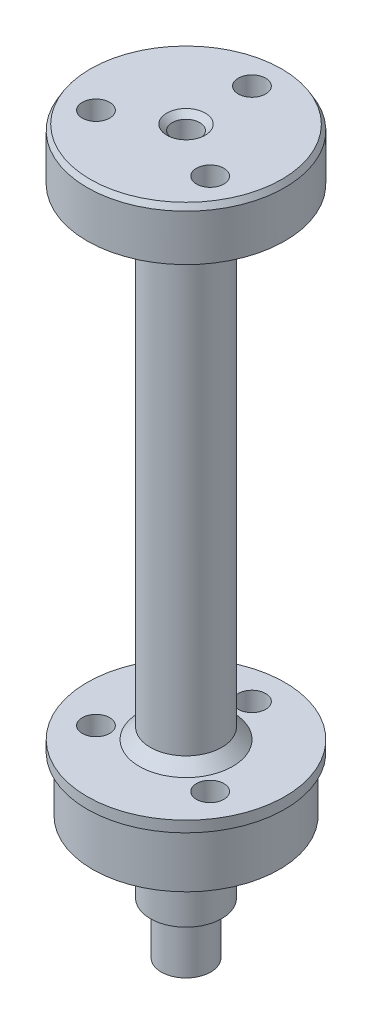
from build123d import *

# Parameters (mm, degrees)
HOLE_WIZARD_M3_1_D           = 2.5
CHAMFER_1_SIZE               = 1
CHAMFER_2_SIZE               = 0.5
CHAMFER_2_SIZE2              = 0.288675135
CHAMFER_2_PART_2_SIZE        = 0.5
CHAMFER_2_PART_2_SIZE2       = 0.288675135
CHAMFER_2_PART_3_SIZE        = 0.5
CHAMFER_2_PART_3_SIZE2       = 0.288675135
HOLE_WIZARD_M3_2_D           = 2.5
HOLE_WIZARD_M3_2_DEPTH       = 6
HOLE_WIZARD_M3_2_CSINK_D     = 3.5
HOLE_WIZARD_M3_2_CSINK_ANGLE = 90
HOLE_WIZARD_M3_2_TIP         = 0.751075774


with BuildPart() as part:
    # 草图2 → 旋转1 (revolve)
    with BuildSketch(Plane.XY):
        Polygon((3.25, 0), (8.5, 0), (8.5, 5), (9, 5), (9, 6), (3.25, 6), (3.25, 49.5), (9, 49.5), (9, 54.5), (1.25, 54.5), (1.25, -11.5), (2.25, -11.5), (2.25, -6.5), (3.25, -6.5), align=None)
    revolve(axis=Axis((0, 60, 0), (0, -1, 0)))

    # M3 螺纹孔1 (through all)
    with Locations(Plane(origin=(0, 54.5, 0), x_dir=(1, 0, 0), z_dir=(0, 1, 0))):
        with Locations((-5.196152423, -3), (0, 6), (5.196152423, -3)):
            Hole(HOLE_WIZARD_M3_1_D / 2)

    # 倒角1
    chamfer_1_edges = [part.edges().sort_by_distance(p)[0] for p in [
        (-3.25, 6, 0),
        (-3.25, 49.5, 0),
    ]]
    chamfer(chamfer_1_edges, length=CHAMFER_1_SIZE)

    # 倒角2
    chamfer_2_edges = [part.edges().sort_by_distance(p)[0] for p in [
        (-9, 49.5, 0),
    ]]
    chamfer_2_side = [part.faces().sort_by_distance(p)[0] for p in [
        (-4.504558441, 49.5, 0),
    ]]
    chamfer(chamfer_2_edges, length=CHAMFER_2_SIZE, length2=CHAMFER_2_SIZE2, reference=chamfer_2_side[0])

    # 倒角2 part 2
    chamfer_2_part_2_edges = [part.edges().sort_by_distance(p)[0] for p in [
        (-9, 54.5, 0),
    ]]
    chamfer_2_part_2_side = [part.faces().sort_by_distance(p)[0] for p in [
        (-9, 52, 0),
    ]]
    chamfer(chamfer_2_part_2_edges, length=CHAMFER_2_PART_2_SIZE, length2=CHAMFER_2_PART_2_SIZE2, reference=chamfer_2_part_2_side[0])

    # 倒角2 part 3
    chamfer_2_part_3_edges = [part.edges().sort_by_distance(p)[0] for p in [
        (-2.25, -11.5, 0),
    ]]
    chamfer_2_part_3_side = [part.faces().sort_by_distance(p)[0] for p in [
        (-1.31363961, -11.5, 0),
    ]]
    chamfer(chamfer_2_part_3_edges, length=CHAMFER_2_PART_3_SIZE, length2=CHAMFER_2_PART_3_SIZE2, reference=chamfer_2_part_3_side[0])

    # M3 螺纹孔2
    with Locations(Plane(origin=(0, 54.5, 0), x_dir=(1, 0, 0), z_dir=(0, 1, 0))):
        with Locations((0, 0)):
            CounterSinkHole(HOLE_WIZARD_M3_2_D / 2, HOLE_WIZARD_M3_2_CSINK_D / 2, depth=HOLE_WIZARD_M3_2_DEPTH, counter_sink_angle=HOLE_WIZARD_M3_2_CSINK_ANGLE)
            with Locations((0, 0, -(HOLE_WIZARD_M3_2_DEPTH + HOLE_WIZARD_M3_2_TIP / 2))):  # 118° drill point
                Cone(0, HOLE_WIZARD_M3_2_D / 2, HOLE_WIZARD_M3_2_TIP, mode=Mode.SUBTRACT)


solid = part.part
